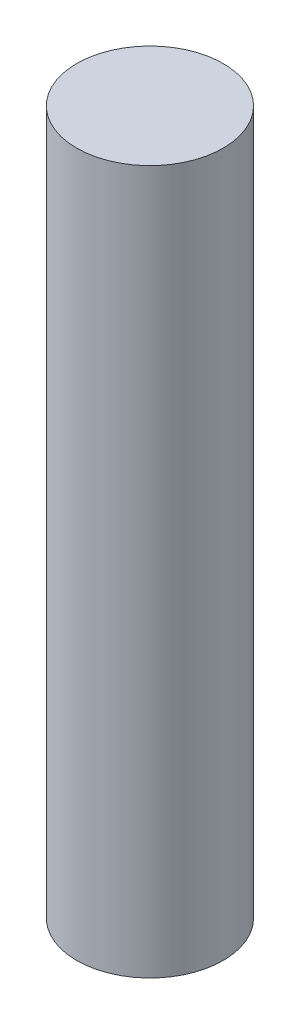
from build123d import *

# Parameters (mm, degrees)
SKETCH1_R           = 7.5
BOSS_EXTRUDE1_DEPTH = 72


with BuildPart() as part:
    # Sketch1 → Boss-Extrude1 (new body)
    with BuildSketch(Plane(origin=(0, 0, 0), x_dir=(1, 0, 0), z_dir=(0, 1, 0))):
        Circle(SKETCH1_R)
    extrude(amount=BOSS_EXTRUDE1_DEPTH)


solid = part.part
